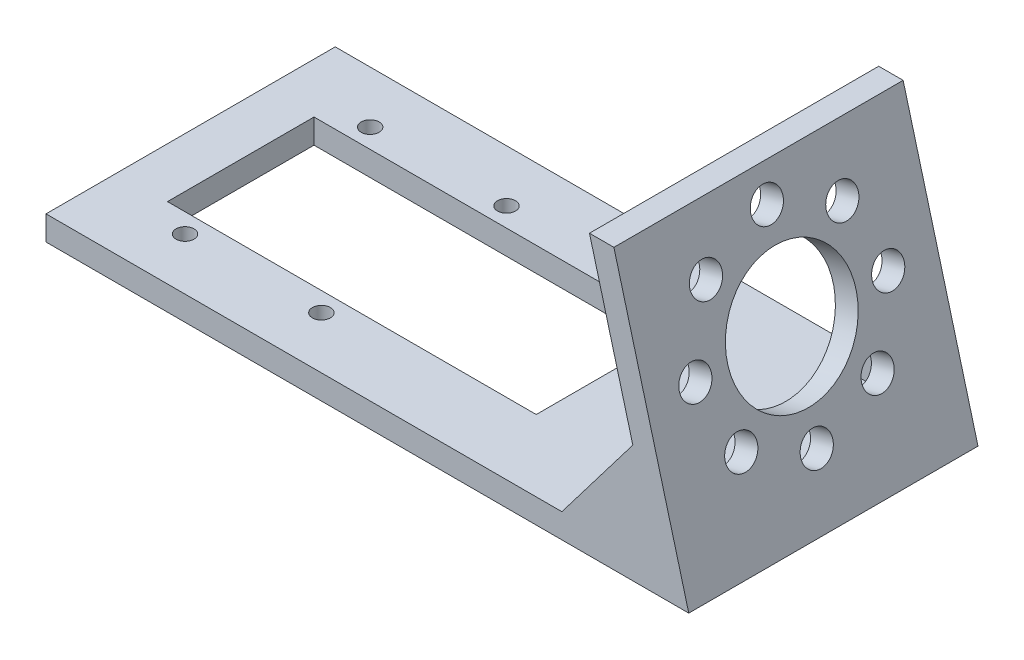
from build123d import *

# Parameters (mm, degrees)
BOSS_EXTRUDE1_DEPTH = 57.15
BOSS_EXTRUDE2_DEPTH = 4.826
CUT_EXTRUDE1_REACH  = 124.673
SKETCH9_R           = 12.7
SKETCH11_R          = 3.175
CUT_EXTRUDE2_DEPTH  = 4.661558
CIRPATTERN1_COUNT   = 8
SKETCH12_R          = 1.778
SKETCH12_W          = 72.86244
SKETCH12_H          = 28.956
CUT_EXTRUDE4_DEPTH  = 5.826


with BuildPart() as part:
    # Sketch3 → Boss-Extrude1 (new body)
    with BuildSketch(Plane.XY):
        Polygon((-49.78, 0), (77.22, 0), (62.428491572, 55.202660972), (57.602491572, 55.202660972), (71.100877197, 4.826), (-49.78, 4.826), align=None)
    extrude(amount=BOSS_EXTRUDE1_DEPTH)

    # Sketch5 → Boss-Extrude2 (add)
    with BuildSketch(Plane.XY.offset(57.15)):
        Polygon((52.148255035, 4.826), (71.100877197, 4.826), (66.170374388, 23.226886991), align=None)
    boss_extrude2 = extrude(amount=-BOSS_EXTRUDE2_DEPTH)

    # Mirror1: Boss-Extrude2 across plane
    add(boss_extrude2.mirror(Plane(origin=(0, 0, 28.575), x_dir=(1, 0, 0), z_dir=(0, 0, -1))))

    # Sketch9 → Cut-Extrude1 (cut, up to next)
    with BuildSketch(Plane(origin=(72.04724084, 19.305, 0), x_dir=(0, 0, -1), z_dir=(0.965925826, 0.258819045, 0)), mode=Mode.PRIVATE) as cut_extrude1_sk1:
        with Locations((-28.575, 11.763993337)):
            Circle(SKETCH9_R)
    cut_extrude1_tool1 = extrude(cut_extrude1_sk1.sketch, amount=-CUT_EXTRUDE1_REACH, mode=Mode.PRIVATE) & part.part
    add(cut_extrude1_tool1.solids().sort_by_distance((69.002495, 30.668145, 28.575))[0], mode=Mode.SUBTRACT)

    # Sketch11 → Cut-Extrude2 (cut)
    with BuildSketch(Plane(origin=(72.04724084, 19.305, 0), x_dir=(0, 0, -1), z_dir=(0.965925826, 0.258819045, 0))):
        with Locations((-28.575, 30.813993337)):
            Circle(SKETCH11_R)
    cut_extrude2 = extrude(amount=-CUT_EXTRUDE2_DEPTH, mode=Mode.SUBTRACT)

    # CirPattern1: Cut-Extrude2 ×8 about axis
    cirpattern1_axis = Axis((-3.044745522, 11.363144985, 28.575), (0.965925826, 0.258819045, 0))
    for i in range(1, CIRPATTERN1_COUNT):
        add(cut_extrude2.rotate(cirpattern1_axis, i * 360 / CIRPATTERN1_COUNT), mode=Mode.SUBTRACT)

    # Sketch12 → Cut-Extrude4 (cut, through all)
    with BuildSketch(Plane(origin=(0, 4.826, 0), x_dir=(1, 0, 0), z_dir=(0, 1, 0))):
        with Locations((-32.595884, -46.863)):
            Circle(SKETCH12_R)
        with Locations((-5.65512, -46.863)):
            Circle(SKETCH12_R)
        with Locations((-3.44278, -28.575)):
            Rectangle(SKETCH12_W, SKETCH12_H)
    cut_extrude4 = extrude(amount=-CUT_EXTRUDE4_DEPTH, mode=Mode.SUBTRACT)

    # Mirror4: Cut-Extrude4 across plane
    add(cut_extrude4.mirror(Plane(origin=(0, 0, 28.575), x_dir=(1, 0, 0), z_dir=(0, 0, -1))), mode=Mode.SUBTRACT)


solid = part.part
